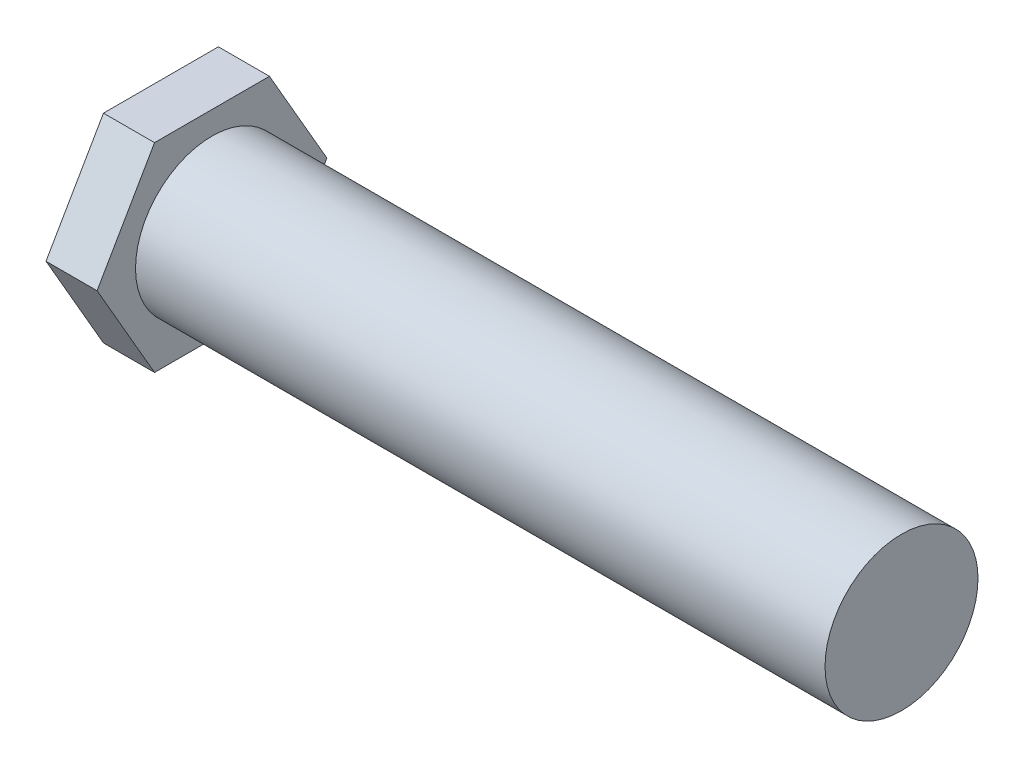
from build123d import *

# Parameters (mm, degrees)
SKETCH1_R           = 29.95
BOSS_EXTRUDE1_DEPTH = 270
BOSS_EXTRUDE2_DEPTH = 20


with BuildPart() as part:
    # Sketch1 → Boss-Extrude1 (new body)
    with BuildSketch(Plane(origin=(0, 0, 0), x_dir=(0, 0, -1), z_dir=(1, 0, 0))):
        Circle(SKETCH1_R)
    extrude(amount=BOSS_EXTRUDE1_DEPTH)

    # Sketch2 → Boss-Extrude2 (add)
    with BuildSketch(Plane.ZY):
        Polygon((45, 0), (22.5, 38.97114317), (-22.5, 38.97114317), (-45, 0), (-22.5, -38.97114317), (22.5, -38.97114317), align=None)
    extrude(amount=BOSS_EXTRUDE2_DEPTH)


solid = part.part
